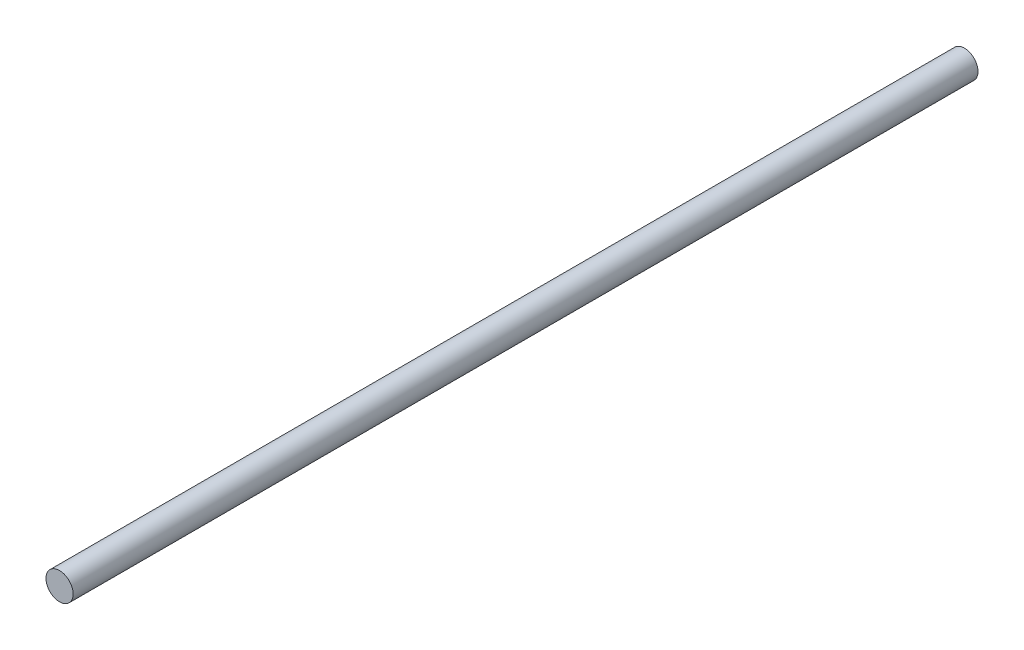
from build123d import *

# Parameters (mm, degrees)
SKETCH_1_R      = 3
EXTRUDE_1_DEPTH = 200


with BuildPart() as part:
    # 草图1 → 凸台-拉伸1 (new body)
    with BuildSketch(Plane.XY):
        Circle(SKETCH_1_R)
    extrude(amount=EXTRUDE_1_DEPTH)


solid = part.part
